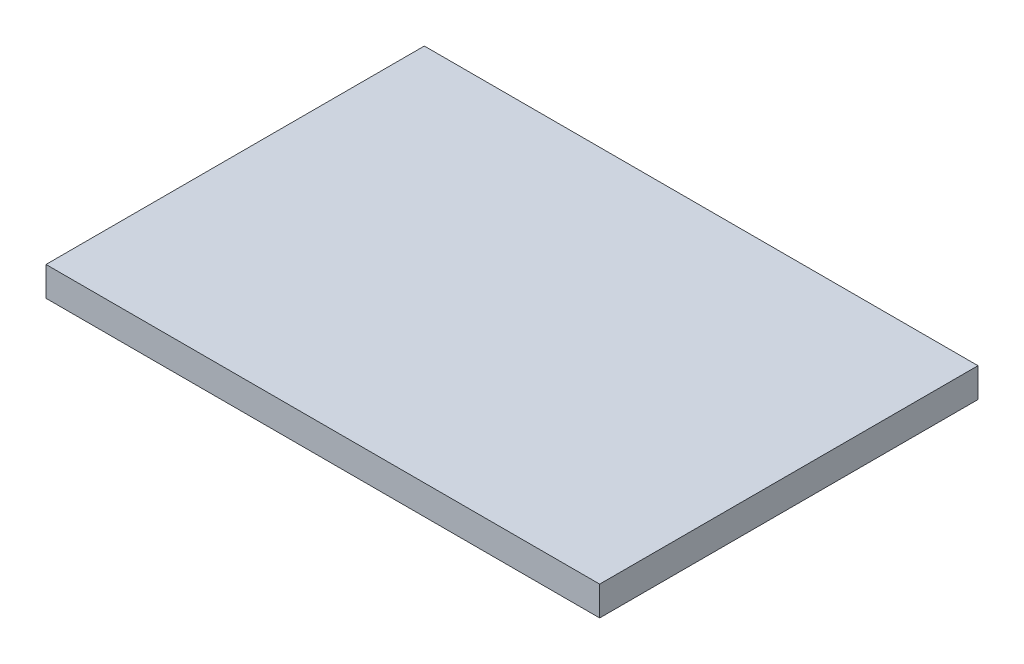
from build123d import *

# Parameters (mm, degrees)
SKETCH3_W           = 30
SKETCH3_H           = 20.5
BOSS_EXTRUDE1_DEPTH = 1.59


with BuildPart() as part:
    # Sketch3 → Boss-Extrude1 (new body)
    with BuildSketch(Plane(origin=(0, 0, 0), x_dir=(1, 0, 0), z_dir=(0, 1, 0))):
        with Locations((15, 10.25)):
            Rectangle(SKETCH3_W, SKETCH3_H)
    extrude(amount=BOSS_EXTRUDE1_DEPTH)


solid = part.part
